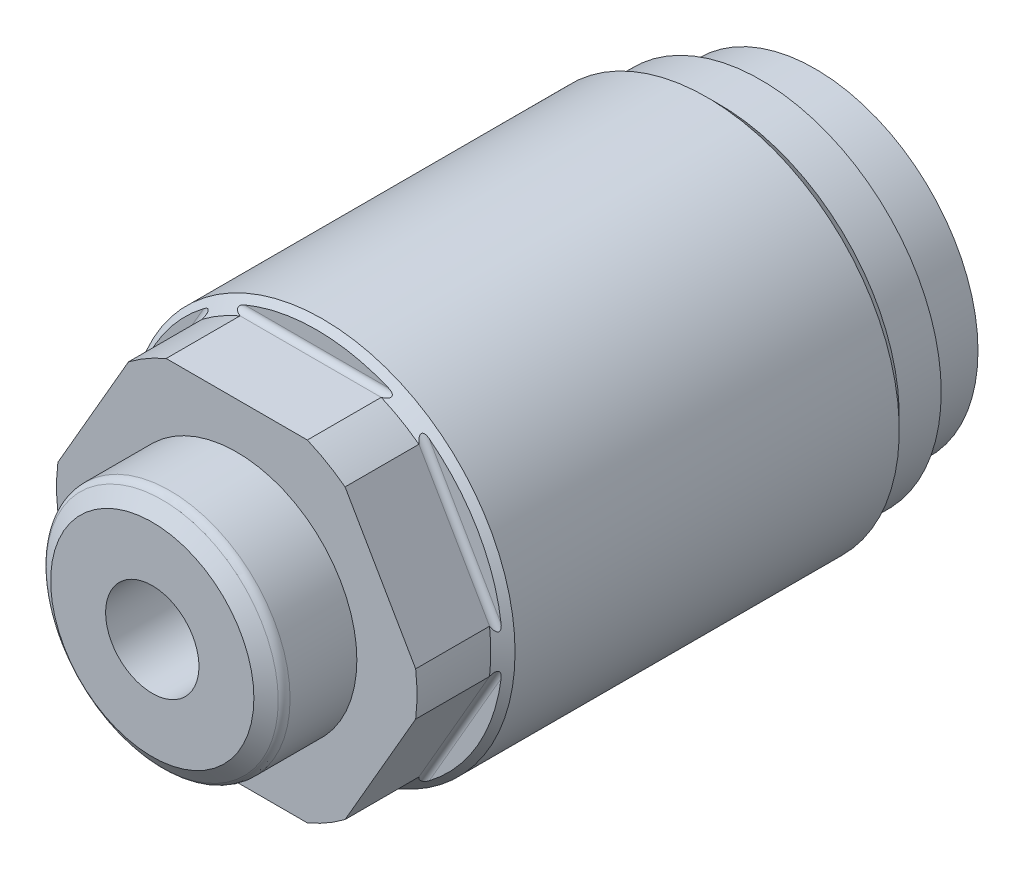
from build123d import *

# Parameters (mm, degrees)
SKETCH1_R          = 16.5354
EXTRUDE1_DEPTH     = 49.7332
CUT_EXTRUDE1_DEPTH = 19.84248
SKETCH12_W         = 4.6736
SKETCH12_H         = 1.5113
SKETCH13_W         = 7.2644
SKETCH13_H         = 10.3251
S2D0011_W          = 4.0132
S2D0011_H          = 9.652
CIRPATTERN2_COUNT  = 6


with BuildPart() as part:
    # Sketch1 → Extrude1 (new body)
    with BuildSketch(Plane.XY):
        Circle(SKETCH1_R)
    extrude(amount=EXTRUDE1_DEPTH)

    # Sketch2 → Cut-Extrude1 (cut, symmetric)
    with BuildSketch(Plane(origin=(0, 0, 0), x_dir=(0, 0, 1), z_dir=(1, 0, 0))):
        with BuildLine():
            Line((42.8752, 16.5354), (42.8752, 14.76375))
            ThreePointArc((42.8752, 14.76375), (43.023989755, 14.404539755), (43.3832, 14.25575))
            Line((43.3832, 14.25575), (49.7332, 14.25575))
            Line((49.7332, 14.25575), (49.7332, 16.5354))
            Line((49.7332, 16.5354), (42.8752, 16.5354))
        make_face()
    cut_extrude1 = extrude(amount=CUT_EXTRUDE1_DEPTH, both=True, mode=Mode.SUBTRACT)

    # Sketch10 → Cut-Revolve1 (revolve, cut)
    with BuildSketch(Plane(origin=(0, 0, 0), x_dir=(0, 0, -1), z_dir=(1, 0, 0)), mode=Mode.PRIVATE) as cut_revolve1_sk:
        Polygon((-49.7332, 15.494), (-43.3832, 15.494), (-42.3418, 16.5354), (-49.7332, 16.5354), align=None)
    revolve(cut_revolve1_sk.sketch.rotate(Axis((0, 0, 50.10277), (0, 0, -1)), 90), axis=Axis((0, 0, 50.10277), (0, 0, -1)), mode=Mode.SUBTRACT)  # turned: the seam where the file's is

    # Sketch11 → Cut-Revolve2 (revolve, cut)
    with BuildSketch(Plane(origin=(0, 0, 0), x_dir=(0, 0, 1), z_dir=(1, 0, 0)), mode=Mode.PRIVATE) as cut_revolve2_sk:
        Polygon((0, 15.5067), (8.2804, 15.5067), (9.3091, 16.5354), (0, 16.5354), align=None)
    revolve(cut_revolve2_sk.sketch.rotate(Axis((0, 0, -0.465455), (0, 0, 1)), 270), axis=Axis((0, 0, -0.465455), (0, 0, 1)), mode=Mode.SUBTRACT)  # turned: the seam where the file's is

    # Sketch12 → Cut-Revolve3 (revolve, cut)
    with BuildSketch(Plane(origin=(0, 0, 0), x_dir=(0, 0, -1), z_dir=(1, 0, 0)), mode=Mode.PRIVATE) as cut_revolve3_sk:
        with Locations((-2.3368, 14.75105)):
            Rectangle(SKETCH12_W, SKETCH12_H)
    revolve(cut_revolve3_sk.sketch.rotate(Axis((0, 0, 4.90728), (0, 0, -1)), 270), axis=Axis((0, 0, 4.90728), (0, 0, -1)), mode=Mode.SUBTRACT)  # turned: the seam where the file's is

    # Sketch13 → Revolve1 (revolve)
    with BuildSketch(Plane(origin=(0, 0, 0), x_dir=(0, 0, -1), z_dir=(1, 0, 0)), mode=Mode.PRIVATE) as revolve1_sk:
        with Locations((-53.3654, 5.16255)):
            Rectangle(SKETCH13_W, SKETCH13_H)
    revolve(revolve1_sk.sketch.rotate(Axis((0, 0, 57.36082), (0, 0, -1)), 270), axis=Axis((0, 0, 57.36082), (0, 0, -1)))  # turned: the seam where the file's is

    # S2D0011 → Cut-Revolve4 (revolve, cut)
    with BuildSketch(Plane(origin=(-4.0132, 0, 56.9976), x_dir=(-1, 0, 0), z_dir=(0, 1, 0))):
        with Locations((-2.0066, -4.826)):
            Rectangle(S2D0011_W, S2D0011_H)
    revolve(axis=Axis((0, 0, 32.002650052), (0, 0, 1)), mode=Mode.SUBTRACT)

    # Sketch15 → Cut-Revolve5 (revolve, cut)
    with BuildSketch(Plane(origin=(0, 0, 0), x_dir=(0, 0, -1), z_dir=(1, 0, 0)), mode=Mode.PRIVATE) as cut_revolve5_sk:
        with BuildLine():
            Line((-56.9976, 8.7376), (-56.142107199, 9.97462236))
            ThreePointArc((-56.142107199, 9.97462236), (-55.851004442, 10.232167854), (-55.4736, 10.3251))
            Line((-55.4736, 10.3251), (-56.9976, 10.3251))
            Line((-56.9976, 10.3251), (-56.9976, 8.7376))
        make_face()
    revolve(cut_revolve5_sk.sketch.rotate(Axis((0, 0, 57.0738), (0, 0, -1)), 270), axis=Axis((0, 0, 57.0738), (0, 0, -1)), mode=Mode.SUBTRACT)  # turned: the seam where the file's is

    # CirPattern2: Cut-Extrude1 ×6 about axis
    cirpattern2_axis = Axis((0, 0, 0), (0, 0, 1))
    for i in range(1, CIRPATTERN2_COUNT):
        add(cut_extrude1.rotate(cirpattern2_axis, i * 360 / CIRPATTERN2_COUNT), mode=Mode.SUBTRACT)


solid = part.part
